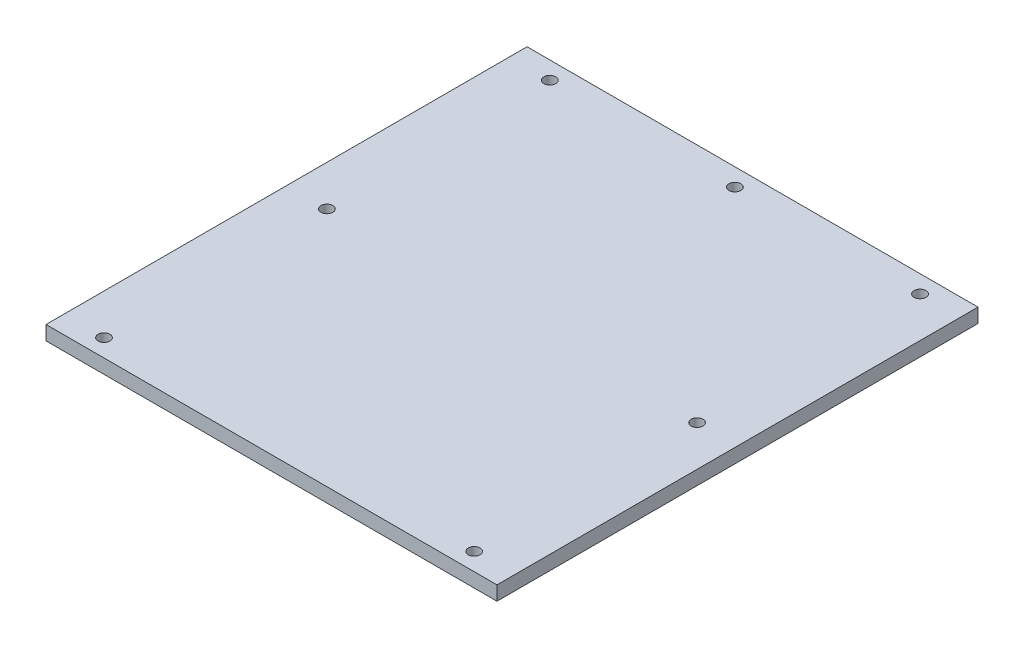
from build123d import *

# Parameters (mm, degrees)
SKETCH2_W           = 190.5
SKETCH2_H           = 203.2
BOSS_EXTRUDE1_DEPTH = 6
SKETCH5_R           = 2.5
CUT_EXTRUDE6_DEPTH  = 7


with BuildPart() as part:
    # Sketch2 → Boss-Extrude1 (new body)
    with BuildSketch(Plane(origin=(0, 0, 0), x_dir=(1, 0, 0), z_dir=(0, 1, 0))):
        Rectangle(SKETCH2_W, SKETCH2_H)
    extrude(amount=BOSS_EXTRUDE1_DEPTH)

    # Sketch5 → Cut-Extrude6 (cut, through all)
    with BuildSketch(Plane(origin=(0, 6, 0), x_dir=(1, 0, 0), z_dir=(0, 1, 0))):
        with Locations((-78.187036158, 94.165073798)):
            Circle(SKETCH5_R)
        with Locations((0, 94.165073798)):
            Circle(SKETCH5_R)
        with Locations((78.187036158, 0)):
            Circle(SKETCH5_R)
        with Locations((-78.187036158, 0)):
            Circle(SKETCH5_R)
        with Locations((78.187036158, 94.165073798)):
            Circle(SKETCH5_R)
        with Locations((-78.187036158, -94.165073798)):
            Circle(SKETCH5_R)
        with Locations((78.187036158, -94.165073798)):
            Circle(SKETCH5_R)
    extrude(amount=-CUT_EXTRUDE6_DEPTH, mode=Mode.SUBTRACT)


solid = part.part
